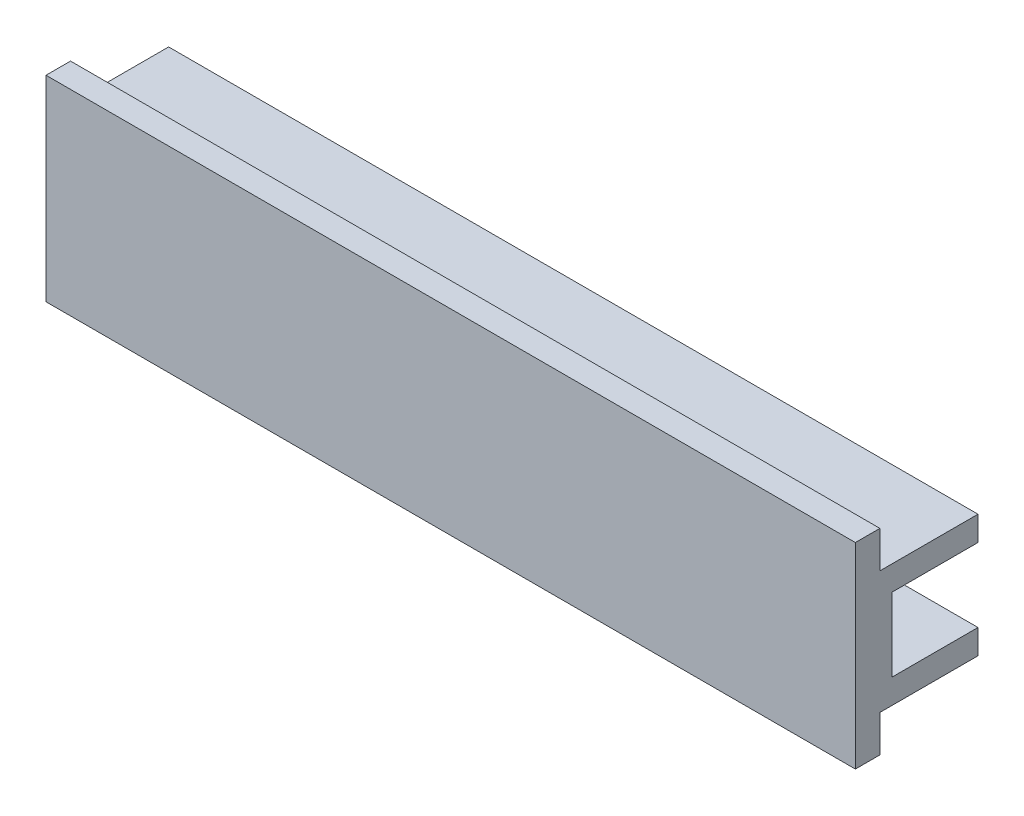
from build123d import *

# Parameters (mm, degrees)
EXTRUDE1_DEPTH = 33
SKETCH2_W      = 1
SKETCH2_H      = 6
EXTRUDE2_DEPTH = 56.5
EXTRUDE3_DEPTH = 1


with BuildPart() as part:
    # Sketch1 → Extrude1 (new body, symmetric)
    with BuildSketch(Plane(origin=(0, 0, 0), x_dir=(0, 0, -1), z_dir=(1, 0, 0))):
        Polygon((-3, 8), (-3, 5), (5, 5), (5, 3), (-2, 3), (-2, -3), (5, -3), (5, -5), (-3, -5), (-3, -8), (-5, -8), (-5, 8), align=None)
    extrude(amount=EXTRUDE1_DEPTH, both=True)

    # Sketch2 → Extrude2 (cut)
    with BuildSketch(Plane.ZY.offset(33)):
        with Locations((2.5, 0)):
            Rectangle(SKETCH2_W, SKETCH2_H)
    extrude(amount=-EXTRUDE2_DEPTH, mode=Mode.SUBTRACT)

    # Sketch3 → Extrude3 (cut)
    with BuildSketch(Plane(origin=(0, 0, 2), x_dir=(-1, 0, 0), z_dir=(0, 0, -1))):
        with BuildLine():
            Line((-23.5, 3), (-23.5, -3))
            ThreePointArc((-23.5, -3), (-26.5, 0), (-23.5, 3))
        make_face()
    extrude(amount=-EXTRUDE3_DEPTH, mode=Mode.SUBTRACT)


solid = part.part
